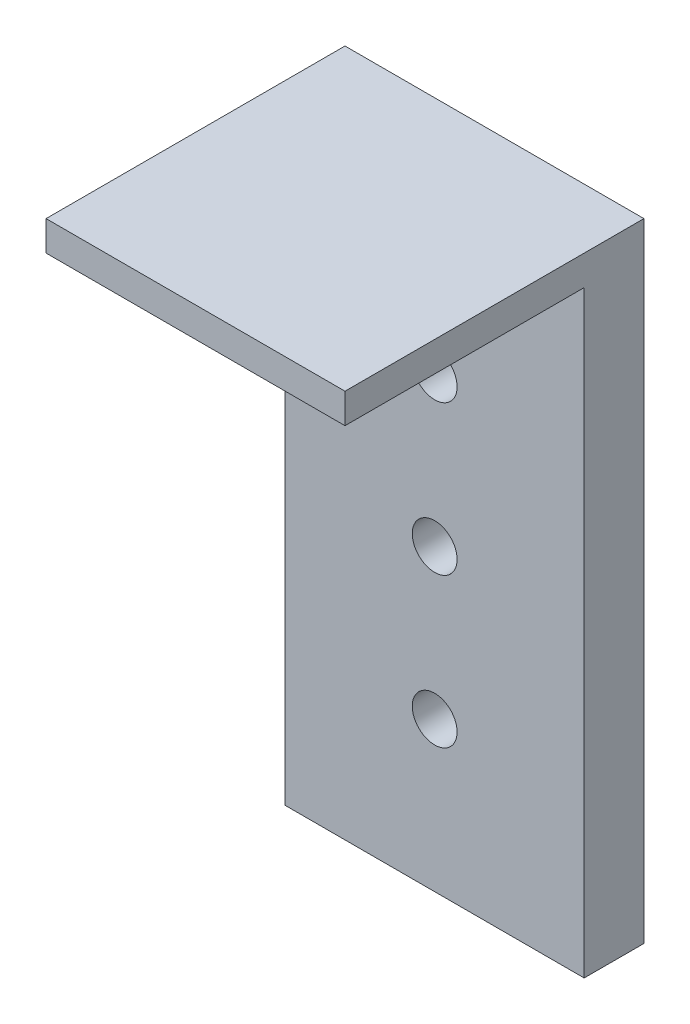
from build123d import *

# Parameters (mm, degrees)
SKETCH1_W           = 10
SKETCH1_H           = 20
BOSS_EXTRUDE1_DEPTH = 2
SKETCH2_R           = 0.75
CUT_EXTRUDE2_DEPTH  = 2
SKETCH5_W           = 10
SKETCH5_H           = 10
BOSS_EXTRUDE2_DEPTH = 1


with BuildPart() as part:
    # Sketch1 → Boss-Extrude1 (new body)
    with BuildSketch(Plane.XY):
        with Locations((5, 19.715051701)):
            Rectangle(SKETCH1_W, SKETCH1_H)
    extrude(amount=BOSS_EXTRUDE1_DEPTH)

    # Sketch2 → Cut-Extrude2 (cut)
    with BuildSketch(Plane.XY):
        with Locations((5, 24.715051701)):
            Circle(SKETCH2_R)
        with Locations((5, 19.715051701)):
            Circle(SKETCH2_R)
        with Locations((5, 14.715051701)):
            Circle(SKETCH2_R)
    extrude(amount=CUT_EXTRUDE2_DEPTH, mode=Mode.SUBTRACT)

    # Sketch5 → Boss-Extrude2 (add)
    with BuildSketch(Plane(origin=(0, 29.715051701, 0), x_dir=(1, 0, 0), z_dir=(0, 1, 0))):
        with Locations((5, -5)):
            Rectangle(SKETCH5_W, SKETCH5_H)
    extrude(amount=BOSS_EXTRUDE2_DEPTH)


solid = part.part
